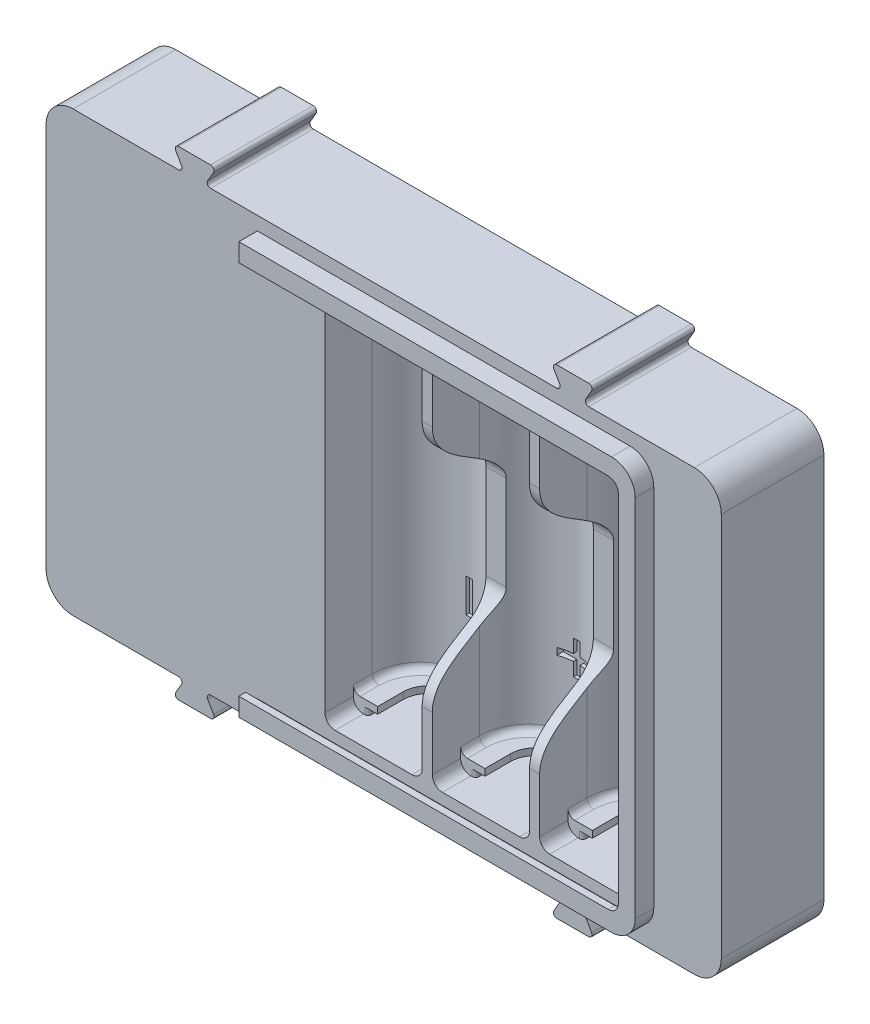
from build123d import *

# Parameters (mm, degrees)
BOSS_EXTRUDE1_DEPTH     = 27.8
SKETCH2_W               = 49.2
SKETCH2_H               = 15.2
BOSS_EXTRUDE2_DEPTH     = 1.5
CUT_EXTRUDE2_DEPTH      = 15
CUT_EXTRUDE2_DEPTH_BACK = 15
INNER_DEPTH             = 1
BOSS_EXTRUDE4_DEPTH     = 1
SKETCH5_W               = 3.4
SKETCH5_H               = 0.5
CUT_EXTRUDE1_DEPTH      = 16.2
SKETCH10_W              = 3.4
SKETCH10_H              = 2
CUT_EXTRUDE6_DEPTH      = 0.6
FILLET2_R               = 1.5
FILLET3_R               = 1
EXTRUDE_START           = -15.2
SKETCH_1_W              = 100
SKETCH_1_H              = 65
EXTRUDE_1_DEPTH         = 15.2
SKETCH_2_W              = 51.7
SKETCH_2_H              = 2
CUT_EXTRUDE_5_DEPTH     = 2
EXTRUDE_3_DEPTH         = 15.2
FILLET_8_R              = 0.5
SKETCH_12_R             = 1.9
CUT_EXTRUDE_2_DEPTH     = 5
FILLET_10_R             = 4
SKETCH_17_W             = 39.8
SKETCH_17_H             = 65
SKETCH_17_W_2           = 11
EXTRUDE_4_DEPTH         = 1
FILLET_13_R             = 4
SKETCH_18_W             = 3.4
SKETCH_18_H             = 2.2
CUT_EXTRUDE_6_DEPTH     = 2
SKETCH_20_W             = 5
SKETCH_20_H             = 1
SKETCH_20_W_2           = 1
SKETCH_20_H_2           = 5
CUT_EXTRUDE_8_DEPTH     = 14.7
EXTRUDE_5_DEPTH         = 1.75
EXTRUDE_6_DEPTH         = 1
FILLET_14_R             = 2.5
FILLET_15_R             = 3.5
FILLET_16_R             = 1.5


with BuildPart() as part:
    # Sketch1 → Boss-Extrude1 (new body)
    with BuildSketch(Plane(origin=(0, 0, 0), x_dir=(1, 0, 0), z_dir=(0, 1, 0))):
        with BuildLine():
            Line((-24.6, 0), (24.6, 0))
            Line((24.6, 0), (24.6, -15.2))
            Line((24.6, -15.2), (23.1, -15.2))
            Line((23.1, -15.2), (23.1, -8.2))
            ThreePointArc((23.1, -8.2), (15.9, -1), (8.7, -8.2))
            Line((8.7, -8.2), (8.7, -15.2))
            Line((8.7, -15.2), (7.2, -15.2))
            Line((7.2, -15.2), (7.2, -8.2))
            ThreePointArc((7.2, -8.2), (0, -1), (-7.2, -8.2))
            Line((-7.2, -8.2), (-7.2, -15.2))
            Line((-7.2, -15.2), (-8.7, -15.2))
            Line((-8.7, -15.2), (-8.7, -8.2))
            ThreePointArc((-8.7, -8.2), (-15.9, -1), (-23.1, -8.2))
            Line((-23.1, -8.2), (-23.1, -15.2))
            Line((-23.1, -15.2), (-24.6, -15.2))
            Line((-24.6, -15.2), (-24.6, 0))
        make_face()
    extrude(amount=BOSS_EXTRUDE1_DEPTH)

    # Sketch2 → Boss-Extrude2 (add)
    with BuildSketch(Plane.XZ.offset(-27.8)):
        with Locations((0, 7.6)):
            Rectangle(SKETCH2_W, SKETCH2_H)
    extrude(amount=-BOSS_EXTRUDE2_DEPTH)

    # Sketch6 → Cut-Extrude2 (cut, two sides)
    with BuildSketch(Plane(origin=(0, 0, 0), x_dir=(0, 0, -1), z_dir=(1, 0, 0))) as cut_extrude2_sk:
        with BuildLine():
            Line((-5, 0), (-15.2, 0))
            Line((-15.2, 0), (-15.2, 18.3))
            add(Edge.make_bspline(
                [(-15.2, 18.3), (-15.2, 12.3), (-5, 11), (-5, 7)],
                knots=[0, 0, 0, 0, 1, 1, 1, 1], degree=3))
            Line((-5, 7), (-5, 0))
        make_face()
    extrude(amount=CUT_EXTRUDE2_DEPTH, mode=Mode.SUBTRACT)
    extrude(cut_extrude2_sk.sketch, amount=-CUT_EXTRUDE2_DEPTH_BACK, mode=Mode.SUBTRACT)

    # Sketch3 → Inner (add)
    with BuildSketch(Plane.XZ.offset(-27.8)):
        with BuildLine():
            Line((-10.4, 11), (-8.7, 11))
            Line((-8.7, 11), (-8.7, 0))
            Line((-8.7, 0), (-23.1, 0))
            Line((-23.1, 0), (-23.1, 11))
            Line((-23.1, 11), (-21.4, 11))
            ThreePointArc((-21.4, 11), (-21.046446609, 10.853553391), (-20.9, 10.5))
            Line((-20.9, 10.5), (-20.9, 3.4))
            ThreePointArc((-20.9, 3.4), (-20.753553391, 3.046446609), (-20.4, 2.9))
            Line((-20.4, 2.9), (-11.4, 2.9))
            ThreePointArc((-11.4, 2.9), (-11.046446609, 3.046446609), (-10.9, 3.4))
            Line((-10.9, 3.4), (-10.9, 10.5))
            ThreePointArc((-10.9, 10.5), (-10.753553391, 10.853553391), (-10.4, 11))
        make_face()
    inner = extrude(amount=INNER_DEPTH)

    # Sketch4 → Boss-Extrude4 (add)
    with BuildSketch(Plane.XZ.offset(-26.8)):
        with BuildLine():
            Line((-8.7, 11), (-8.7, 0))
            Line((-8.7, 0), (-23.1, 0))
            Line((-23.1, 0), (-23.1, 11))
            Line((-23.1, 11), (-19.5, 11))
            Line((-19.5, 11), (-19.5, 7.2))
            ThreePointArc((-19.5, 7.2), (-15.9, 3.6), (-12.3, 7.2))
            Line((-12.3, 7.2), (-12.3, 11))
            Line((-12.3, 11), (-8.7, 11))
        make_face()
    boss_extrude4 = extrude(amount=BOSS_EXTRUDE4_DEPTH)

    # Sketch5 → Cut-Extrude1 (cut, through all)
    with BuildSketch(Plane.XY.offset(15.2)):
        with Locations((-15.9, 27.55)):
            Rectangle(SKETCH5_W, SKETCH5_H)
    cut_extrude1 = extrude(amount=-CUT_EXTRUDE1_DEPTH, mode=Mode.SUBTRACT)

    # Sketch10 → Cut-Extrude6 (cut)
    with BuildSketch(Plane.XY):
        with Locations((-15.9, 28.3)):
            Rectangle(SKETCH10_W, SKETCH10_H)
    cut_extrude6 = extrude(amount=CUT_EXTRUDE6_DEPTH, mode=Mode.SUBTRACT)

    # Mirror1: Inner, Boss-Extrude4, Cut-Extrude1, Cut-Extrude6 across plane
    add(inner.mirror(Plane(origin=(0, 0, 0), x_dir=(0, 0, 1), z_dir=(1, 0, 0))))
    add(boss_extrude4.mirror(Plane(origin=(0, 0, 0), x_dir=(0, 0, 1), z_dir=(1, 0, 0))))
    add(cut_extrude1.mirror(Plane(origin=(0, 0, 0), x_dir=(0, 0, 1), z_dir=(1, 0, 0))), mode=Mode.SUBTRACT)
    add(cut_extrude6.mirror(Plane(origin=(0, 0, 0), x_dir=(0, 0, 1), z_dir=(1, 0, 0))), mode=Mode.SUBTRACT)

    # Mirror2: Inner, Boss-Extrude4, Cut-Extrude1, Cut-Extrude6 across plane
    add(inner.mirror(Plane(origin=(-7.95, 0, 0), x_dir=(0, 0, 1), z_dir=(1, 0, 0))))
    add(boss_extrude4.mirror(Plane(origin=(-7.95, 0, 0), x_dir=(0, 0, 1), z_dir=(1, 0, 0))))
    add(cut_extrude1.mirror(Plane(origin=(-7.95, 0, 0), x_dir=(0, 0, 1), z_dir=(1, 0, 0))), mode=Mode.SUBTRACT)
    add(cut_extrude6.mirror(Plane(origin=(-7.95, 0, 0), x_dir=(0, 0, 1), z_dir=(1, 0, 0))), mode=Mode.SUBTRACT)

    # Fillet2
    fillet2_edges = [part.edges().sort_by_distance(p)[0] for p in [
        (-8.7, 27.8, 13.1),
        (-23.1, 27.8, 13.1),
        (23.1, 27.8, 13.1),
        (-7.2, 27.8, 13.1),
        (7.2, 27.8, 13.1),
        (8.7, 27.8, 13.1),
    ]]
    fillet(fillet2_edges, radius=FILLET2_R)

    # Fillet3
    fillet3_edges = [part.edges().sort_by_distance(p)[0] for p in [
        (-8.7, 25.8, 9.6),
        (-23.1, 25.8, 9.6),
        (-15.9, 25.8, 1),
        (8.7, 25.8, 9.6),
        (23.1, 25.8, 9.6),
        (15.9, 25.8, 1),
        (-7.2, 25.8, 9.6),
        (7.2, 25.8, 9.6),
        (0, 25.8, 1),
    ]]
    fillet(fillet3_edges, radius=FILLET3_R)

    # Mirror4: part across plane


with BuildPart() as part_1:
    add(part.part)
    add(part.part.mirror(Plane.ZX))

    # Эскиз1 → Бобышка-Вытянуть1 (add)
    with BuildSketch(Plane(origin=(0, 0, 0), x_dir=(-1, 0, 0), z_dir=(0, 0, -1)).offset(EXTRUDE_START)):
        with Locations((14.4, 0)):
            Rectangle(SKETCH_1_W, SKETCH_1_H)
        Polygon((-24.6, -29.3), (-24.6, -24), (-34.6, -24), (-34.6, 24), (-24.6, 24), (-24.6, 29.3), (24.6, 29.3), (24.6, 31.5), (55.9, 31.5), (55.9, 24), (63.4, 24), (63.4, -24), (55.9, -24), (55.9, -31.5), (24.6, -31.5), (24.6, -29.3), align=None, mode=Mode.SUBTRACT)
    extrude(amount=EXTRUDE_1_DEPTH)

    # Эскиз2 → Вырез-Вытянуть5 (cut)
    with BuildSketch(Plane(origin=(0, 0, 0), x_dir=(-1, 0, 0), z_dir=(0, 0, -1))):
        with Locations((-1.25, -30.5)):
            Rectangle(SKETCH_2_W, SKETCH_2_H)
        with Locations((-1.25, 30.5)):
            Rectangle(SKETCH_2_W, SKETCH_2_H)
    extrude(amount=-CUT_EXTRUDE_5_DEPTH, mode=Mode.SUBTRACT)

    # Эскиз11 → Бобышка-Вытянуть3 (add)
    with BuildSketch(Plane.XY.offset(15.2)):
        Polygon((-43.9, 32.5), (-45.632050808, 35.5), (-39.167949192, 35.5), (-40.9, 32.5), align=None)
        Polygon((12.1, 32.5), (10.367949192, 35.5), (16.832050808, 35.5), (15.1, 32.5), align=None)
        Polygon((-43.9, -32.5), (-45.632050808, -35.5), (-39.167949192, -35.5), (-40.9, -32.5), align=None)
        Polygon((12.1, -32.5), (10.367949192, -35.5), (16.832050808, -35.5), (15.1, -32.5), align=None)
    extrude(amount=-EXTRUDE_3_DEPTH)

    # Скругление8
    fillet_8_edges = [part_1.edges().sort_by_distance(p)[0] for p in [
        (-40.9, 32.5, 7.6),
        (-43.9, 32.5, 7.6),
        (-45.632050808, 35.5, 7.6),
        (-39.167949192, 35.5, 7.6),
        (15.1, 32.5, 7.6),
        (12.1, 32.5, 7.6),
        (10.367949192, 35.5, 7.6),
        (16.832050808, 35.5, 7.6),
        (12.1, -32.5, 7.6),
        (15.1, -32.5, 7.6),
        (16.832050808, -35.5, 7.6),
        (10.367949192, -35.5, 7.6),
        (-40.9, -32.5, 7.6),
        (-39.167949192, -35.5, 7.6),
        (-45.632050808, -35.5, 7.6),
        (-43.9, -32.5, 7.6),
    ]]
    fillet(fillet_8_edges, radius=FILLET_8_R)

    # Эскиз12 → Вырез-Вытянуть2 (cut)
    with BuildSketch(Plane(origin=(0, 0, 0), x_dir=(-1, 0, 0), z_dir=(0, 0, -1))):
        with Locations((-31.1, 28)):
            Circle(SKETCH_12_R)
        with Locations((59.9, 28)):
            Circle(SKETCH_12_R)
        with Locations((59.9, -28)):
            Circle(SKETCH_12_R)
        with Locations((-31.1, -28)):
            Circle(SKETCH_12_R)
    extrude(amount=-CUT_EXTRUDE_2_DEPTH, mode=Mode.SUBTRACT)

    # Скругление10
    fillet_10_edges = [part_1.edges().sort_by_distance(p)[0] for p in [
        (-55.9, 24, 7.6),
        (-55.9, -24, 7.6),
    ]]
    fillet(fillet_10_edges, radius=FILLET_10_R)

    # Эскиз17 → Бобышка-Вытянуть4 (add)
    with BuildSketch(Plane.XY.offset(15.2)):
        with Locations((-44.5, 0)):
            Rectangle(SKETCH_17_W, SKETCH_17_H)
        with Locations((30.1, 0)):
            Rectangle(SKETCH_17_W_2, SKETCH_17_H)
    extrude(amount=-EXTRUDE_4_DEPTH)

    # Скругление13
    fillet_13_edges = [part_1.edges().sort_by_distance(p)[0] for p in [
        (-64.4, 32.5, 7.6),
        (35.6, 32.5, 7.6),
        (35.6, -32.5, 7.6),
        (-64.4, -32.5, 7.6),
    ]]
    fillet(fillet_13_edges, radius=FILLET_13_R)

    # Эскиз18 → Вырез-Вытянуть6 (cut)
    with BuildSketch(Plane(origin=(0, 0, 0), x_dir=(-1, 0, 0), z_dir=(0, 0, -1))):
        with Locations((-15.9, 28.4)):
            Rectangle(SKETCH_18_W, SKETCH_18_H)
        with Locations((0, 28.4)):
            Rectangle(SKETCH_18_W, SKETCH_18_H)
        with Locations((15.9, 28.4)):
            Rectangle(SKETCH_18_W, SKETCH_18_H)
        with Locations((15.9, -28.4)):
            Rectangle(SKETCH_18_W, SKETCH_18_H)
        with Locations((0, -28.4)):
            Rectangle(SKETCH_18_W, SKETCH_18_H)
        with Locations((-15.9, -28.4)):
            Rectangle(SKETCH_18_W, SKETCH_18_H)
    extrude(amount=-CUT_EXTRUDE_6_DEPTH, mode=Mode.SUBTRACT)

    # Эскиз20 → Вырез-Вытянуть8 (cut)
    with BuildSketch(Plane.XY.offset(15.2)):
        with Locations((-15.9, 15)):
            Rectangle(SKETCH_20_W, SKETCH_20_H)
        with Locations((-15.9, 15)):
            Rectangle(SKETCH_20_W_2, SKETCH_20_H_2)
        with Locations((-15.9, -15)):
            Rectangle(SKETCH_20_W_2, SKETCH_20_H_2)
        with Locations((0, 15)):
            Rectangle(SKETCH_20_W_2, SKETCH_20_H_2)
        with Locations((15.9, 15)):
            Rectangle(SKETCH_20_W_2, SKETCH_20_H_2)
        with Locations((15.9, -15)):
            Rectangle(SKETCH_20_W_2, SKETCH_20_H_2)
        with Locations((0, -15)):
            Rectangle(SKETCH_20_W_2, SKETCH_20_H_2)
        with Locations((15.9, 15)):
            Rectangle(SKETCH_20_W, SKETCH_20_H)
        with Locations((0, -15)):
            Rectangle(SKETCH_20_W, SKETCH_20_H)
    extrude(amount=-CUT_EXTRUDE_8_DEPTH, mode=Mode.SUBTRACT)

    # Эскиз22 → Бобышка-Вытянуть5 (add)
    with BuildSketch(Plane.XY.offset(15.2)):
        Polygon((-33.1, 29.5), (24.6, 29.5), (24.6, -29.5), (-33.1, -29.5), (-33.1, -30.5), (25.6, -30.5), (25.6, 30.5), (-33.1, 30.5), align=None)
    extrude(amount=EXTRUDE_5_DEPTH)

    # Эскиз23 → Бобышка-Вытянуть6 (add)
    with BuildSketch(Plane.XY.offset(16.95)):
        Polygon((-33.1, 30.5), (-33.1, 27.8), (23.1, 27.8), (23.1, -27.8), (-33.1, -27.8), (-33.1, -30.5), (25.6, -30.5), (25.6, 30.5), align=None)
    extrude(amount=EXTRUDE_6_DEPTH)

    # Скругление14
    fillet_14_edges = [part_1.edges().sort_by_distance(p)[0] for p in [
        (24.6, 29.5, 16.075),
        (24.6, -29.5, 16.075),
    ]]
    fillet(fillet_14_edges, radius=FILLET_14_R)

    # Скругление15
    fillet_15_edges = [part_1.edges().sort_by_distance(p)[0] for p in [
        (25.6, -30.5, 16.575),
        (25.6, 30.5, 16.575),
    ]]
    fillet(fillet_15_edges, radius=FILLET_15_R)

    # Скругление16
    fillet_16_edges = [part_1.edges().sort_by_distance(p)[0] for p in [
        (23.1, 27.8, 17.45),
        (23.1, -27.8, 17.45),
    ]]
    fillet(fillet_16_edges, radius=FILLET_16_R)


solid = part_1.part
